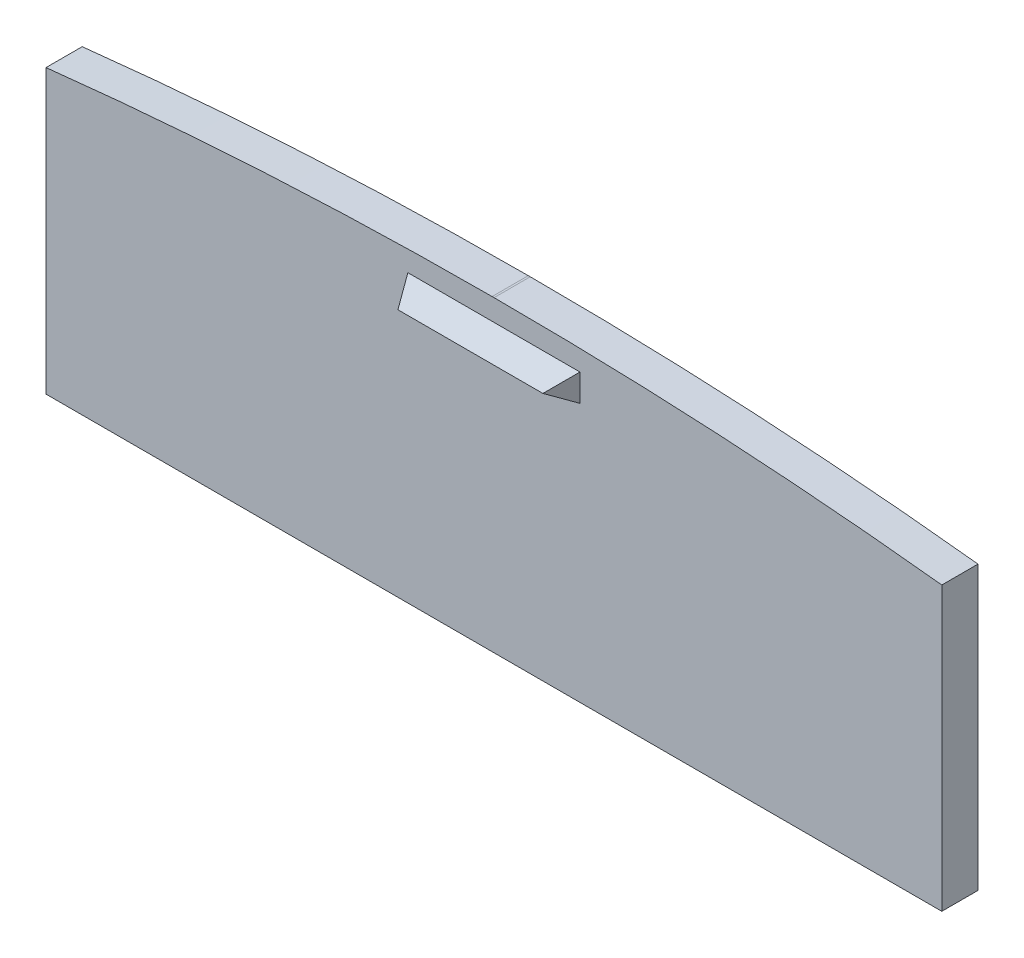
from build123d import *

# Parameters (mm, degrees)
BOSS_EXTRU_2_DEPTH = 4
ESQUISSE6_W        = 19.024162062
ESQUISSE6_H        = 3
BOSS_EXTRU_3_DEPTH = 3
BOSS_EXTRU_3_TAPER = 30


with BuildPart() as part:
    # Esquisse2 → Boss.-Extru.2 (new body)
    with BuildSketch(Plane.XY):
        with BuildLine():
            Line((15.843049481, 153.91195697), (15.843049481, 122.649102361))
            Line((15.843049481, 122.649102361), (114.867211543, 122.649102361))
            Line((114.867211543, 122.649102361), (114.867211543, 153.891733148))
            ThreePointArc((114.867211543, 153.891733148), (90.104041762, 155.959238078), (65.264290885, 156.649115353))
            ThreePointArc((65.264290885, 156.649115353), (40.515800335, 155.964301811), (15.843049481, 153.91195697))
        make_face()
    extrude(amount=BOSS_EXTRU_2_DEPTH)

    # Esquisse6 → Boss.-Extru.3 (add)
    with BuildSketch(Plane.XY.offset(4)):
        with Locations((65.355130512, 152.77778229)):
            Rectangle(ESQUISSE6_W, ESQUISSE6_H)
    extrude(amount=BOSS_EXTRU_3_DEPTH, taper=BOSS_EXTRU_3_TAPER)


solid = part.part
